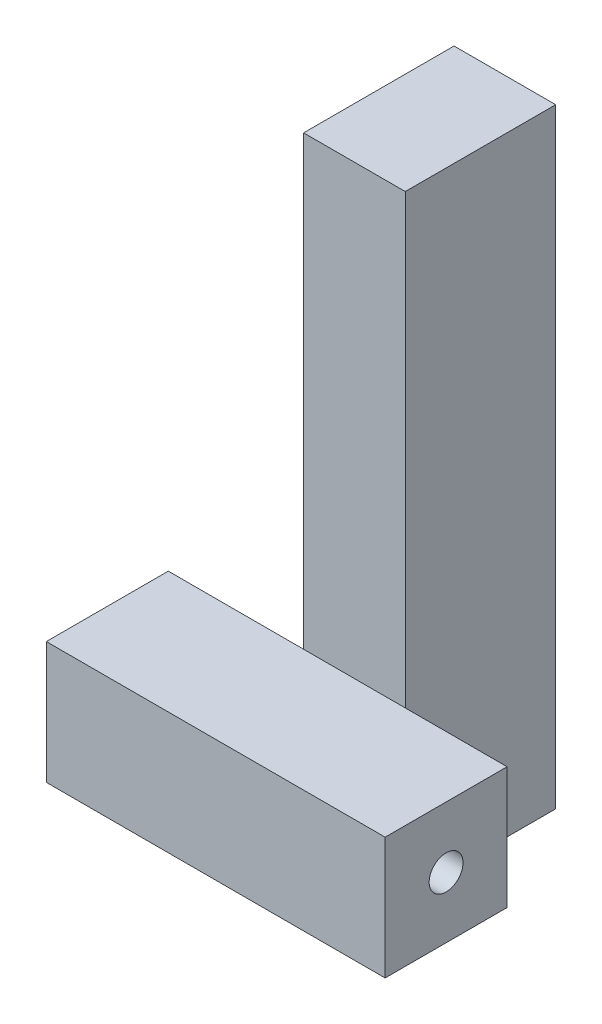
from build123d import *

# Parameters (mm, degrees)
SKETCH1_W           = 127
SKETCH1_H           = 45.72
BOSS_EXTRUDE1_DEPTH = 45.72
SKETCH2_W           = 38.1
SKETCH2_H           = 228.6
BOSS_EXTRUDE2_DEPTH = 56.388
SKETCH3_R           = 6.35
CUT_EXTRUDE1_DEPTH  = 15.24
SKETCH4_R           = 6.35
CUT_EXTRUDE2_DEPTH  = 15.24


with BuildPart() as part:
    # Sketch1 → Boss-Extrude1 (new body)
    with BuildSketch(Plane.XY):
        Rectangle(SKETCH1_W, SKETCH1_H)
    extrude(amount=BOSS_EXTRUDE1_DEPTH)

    # Sketch2 → Boss-Extrude2 (add)
    with BuildSketch(Plane(origin=(0, 0, 0), x_dir=(-1, 0, 0), z_dir=(0, 0, -1))):
        with Locations((-6.276150489, 76.2)):
            Rectangle(SKETCH2_W, SKETCH2_H)
    extrude(amount=BOSS_EXTRUDE2_DEPTH)

    # Sketch3 → Cut-Extrude1 (cut)
    with BuildSketch(Plane(origin=(63.5, 0, 0), x_dir=(0, 0, -1), z_dir=(1, 0, 0))):
        with Locations((-22.86, 0)):
            Circle(SKETCH3_R)
    extrude(amount=-CUT_EXTRUDE1_DEPTH, mode=Mode.SUBTRACT)

    # Sketch4 → Cut-Extrude2 (cut)
    with BuildSketch(Plane.ZY.offset(63.5)):
        with Locations((22.86, 0)):
            Circle(SKETCH4_R)
    extrude(amount=-CUT_EXTRUDE2_DEPTH, mode=Mode.SUBTRACT)


solid = part.part
